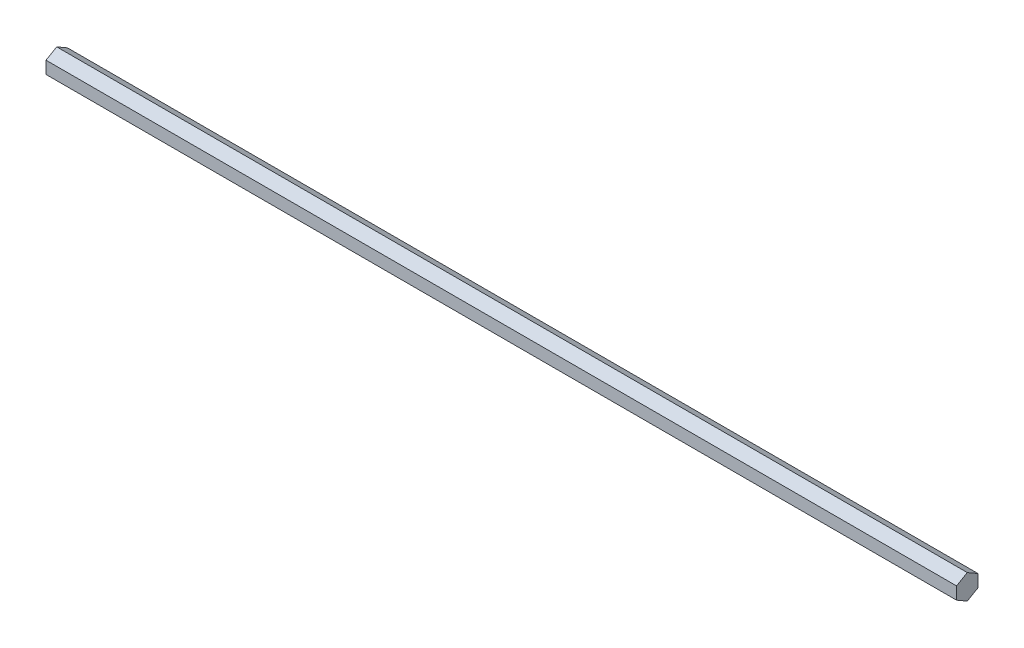
from build123d import *

# Parameters (mm, degrees)
BOSS_EXTRUDE1_DEPTH = 539.75


with BuildPart() as part:
    # Sketch1 → Boss-Extrude1 (new body)
    with BuildSketch(Plane(origin=(0, 0, 0), x_dir=(0, 0, -1), z_dir=(1, 0, 0))):
        Polygon((0, 7.332348419), (-6.35, 3.666174209), (-6.35, -3.666174209), (0, -7.332348419), (6.35, -3.666174209), (6.35, 3.666174209), align=None)
    extrude(amount=BOSS_EXTRUDE1_DEPTH)


solid = part.part
